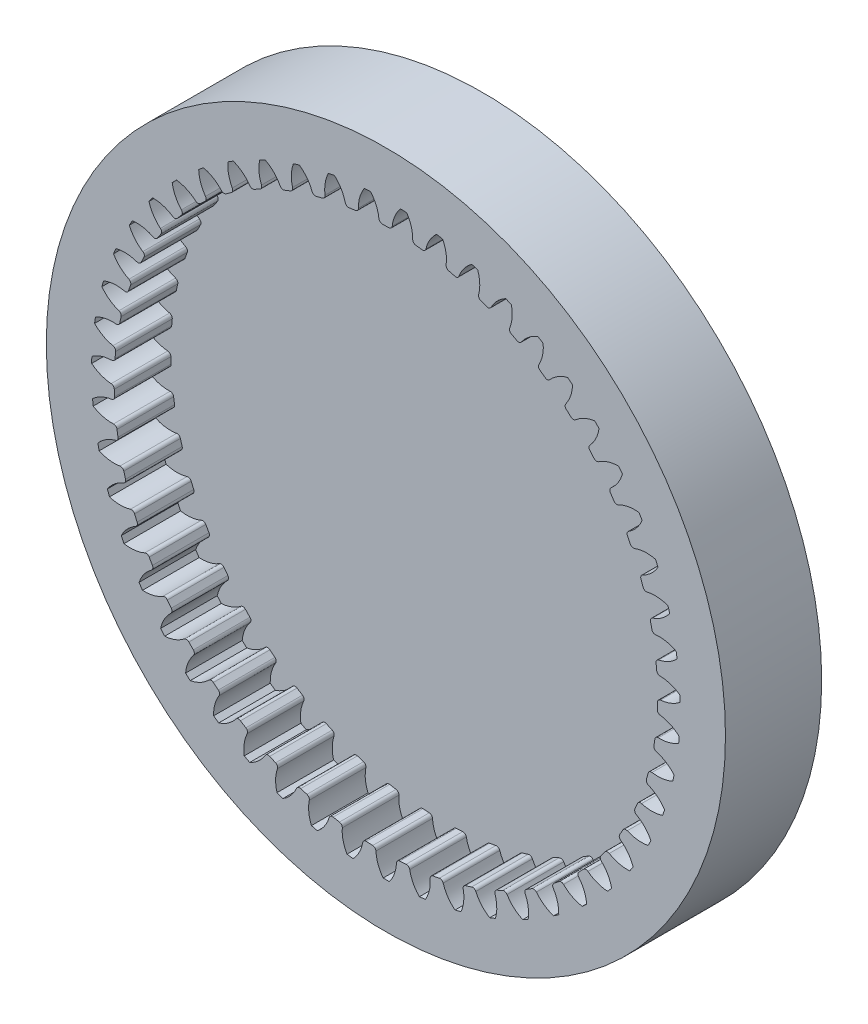
from build123d import *

# Parameters (mm, degrees)
SKETCH1_R           = 60
BOSS_EXTRUDE1_DEPTH = 10
CUT_EXTRUDE2_DEPTH  = 11
CIRPATTERN2_COUNT   = 51
SKETCH6_R           = 48
CUT_EXTRUDE3_DEPTH  = 11
SKETCH8_R           = 60
BOSS_EXTRUDE3_DEPTH = 7
CUT_EXTRUDE4_DEPTH  = 6


with BuildPart() as part:
    # Sketch1 → Boss-Extrude1 (new body)
    with BuildSketch(Plane.XY):
        Circle(SKETCH1_R)
    extrude(amount=BOSS_EXTRUDE1_DEPTH)

    # Sketch5 → Cut-Extrude2 (cut, through all)
    with BuildSketch(Plane(origin=(0, 0, 0), x_dir=(-1, 0, 0), z_dir=(0, 0, -1))):
        with BuildLine():
            ThreePointArc((2.716613684, 51.928990074), (1.716892954, 50.341251638), (1.231241814, 48.528933275))
            ThreePointArc((1.231241814, 48.528933275), (1.031960133, 48.145950609), (0.627145887, 47.995902826))
            ThreePointArc((0.627145887, 47.995902826), (3.013944937, 47.905282965), (5.393281044, 47.696043018))
            ThreePointArc((5.393281044, 47.696043018), (5.010464854, 47.895644308), (4.860755025, 48.300583659))
            ThreePointArc((4.860755025, 48.300583659), (4.606077109, 50.159479578), (3.813235868, 51.859996454))
            ThreePointArc((3.813235868, 51.859996454), (3.265107016, 51.897389878), (2.716613684, 51.928990074))
        make_face()
    cut_extrude2 = extrude(amount=-CUT_EXTRUDE2_DEPTH, mode=Mode.SUBTRACT)

    # CirPattern2: Cut-Extrude2 ×51 about axis
    cirpattern2_axis = Axis((0, 0, 0), (0, 0, 1))
    for i in range(1, CIRPATTERN2_COUNT):
        add(cut_extrude2.rotate(cirpattern2_axis, i * 360 / CIRPATTERN2_COUNT), mode=Mode.SUBTRACT)

    # Sketch6 → Cut-Extrude3 (cut, through all)
    with BuildSketch(Plane(origin=(0, 0, 0), x_dir=(-1, 0, 0), z_dir=(0, 0, -1))):
        Circle(SKETCH6_R)
    extrude(amount=-CUT_EXTRUDE3_DEPTH, mode=Mode.SUBTRACT)

    # Sketch8 → Boss-Extrude3 (add)
    with BuildSketch(Plane(origin=(0, 0, 0), x_dir=(-1, 0, 0), z_dir=(0, 0, -1))):
        Circle(SKETCH8_R)
    extrude(amount=BOSS_EXTRUDE3_DEPTH)

    # Sketch9 → Cut-Extrude4 (cut)
    with BuildSketch(Plane(origin=(0, 0, -7), x_dir=(-1, 0, 0), z_dir=(0, 0, -1))):
        with BuildLine():
            Line((-9.4630292, -3.232812763), (1.315965341, 9.913033603))
            ThreePointArc((1.315965341, 9.913033603), (7.732850804, -6.340585024), (-9.4630292, -3.232812763))
        make_face()
    extrude(amount=-CUT_EXTRUDE4_DEPTH, mode=Mode.SUBTRACT)


solid = part.part
